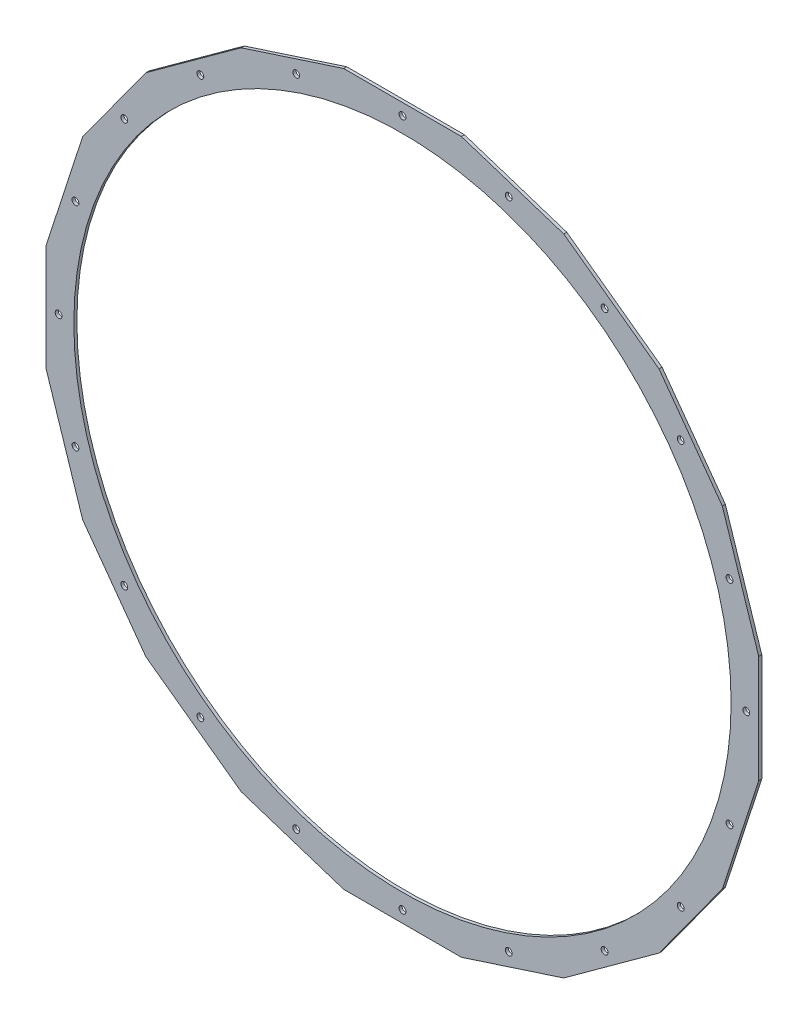
from build123d import *

# Parameters (mm, degrees)
SKETCH1_R          = 375.92
SKETCH1_R_2        = 342.9
EXTRUDE1_DEPTH     = 3.175
SKETCH2_R          = 3.556
CUT_EXTRUDE1_DEPTH = 3.175
CIRPATTERN1_COUNT  = 20
CUT_EXTRUDE3_DEPTH = 3.175
CIRPATTERN2_COUNT  = 10


with BuildPart() as part:
    # Sketch1 → Extrude1 (new body)
    with BuildSketch(Plane.XY):
        Circle(SKETCH1_R)
        Circle(SKETCH1_R_2, mode=Mode.SUBTRACT)
    extrude(amount=EXTRUDE1_DEPTH)

    # Sketch2 → Cut-Extrude1 (cut)
    with BuildSketch(Plane.XY.offset(3.175)):
        with Locations((0, -358.775)):
            Circle(SKETCH2_R)
    cut_extrude1 = extrude(amount=-CUT_EXTRUDE1_DEPTH, mode=Mode.SUBTRACT)

    # CirPattern1: Cut-Extrude1 ×20 about axis
    cirpattern1_axis = Axis((0, 0, 0), (0, 0, 1))
    for i in range(1, CIRPATTERN1_COUNT):
        add(cut_extrude1.rotate(cirpattern1_axis, i * 360 / CIRPATTERN1_COUNT), mode=Mode.SUBTRACT)

    # Sketch3 → Cut-Extrude3 (cut)
    with BuildSketch(Plane.XY.offset(3.175)):
        Polygon((168.294733652, -336.143911182), (61.426903046, -370.867337443), (-61.427134053, -370.867299181), (-80.587451942, -486.54802329), (220.789134468, -440.993735193), align=None)
    cut_extrude3 = extrude(amount=-CUT_EXTRUDE3_DEPTH, mode=Mode.SUBTRACT)

    # CirPattern2: Cut-Extrude3 ×10 about axis
    cirpattern2_axis = Axis((0, 0, 0), (0, 0, 1))
    for i in range(1, CIRPATTERN2_COUNT):
        add(cut_extrude3.rotate(cirpattern2_axis, i * 360 / CIRPATTERN2_COUNT), mode=Mode.SUBTRACT)


solid = part.part
